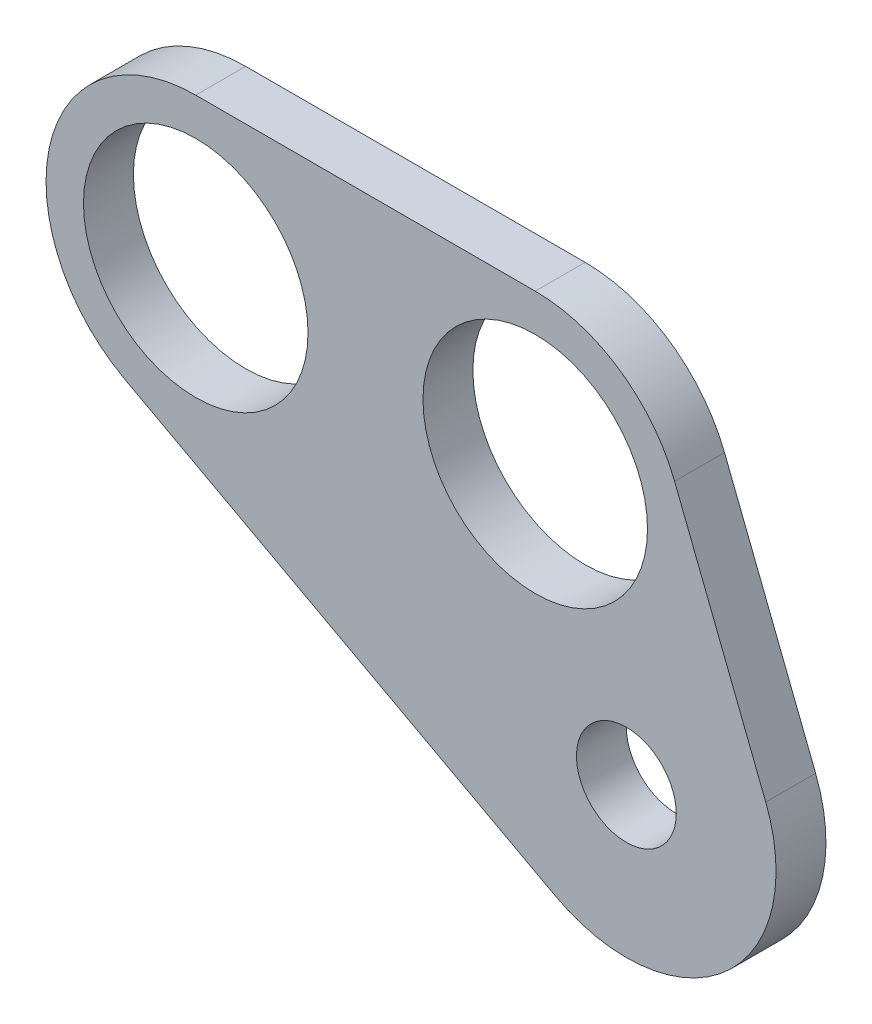
from build123d import *

# Parameters (mm, degrees)
BOSS_EXTRUDE1_DEPTH            = 6.35
F_1_1_DIAMETER_HOLE1_D         = 28.575
F_1_1_DIAMETER_HOLE1_DEPTH     = 25.4
F_1_1_DIAMETER_HOLE1_TIP       = 8.584796094
F_1_2_0_5_DIAMETER_HOLE1_D     = 12.7
F_1_2_0_5_DIAMETER_HOLE1_DEPTH = 25.4
F_1_2_0_5_DIAMETER_HOLE1_TIP   = 3.815464931


with BuildPart() as part:
    # Sketch1 → Boss-Extrude1 (new body)
    with BuildSketch(Plane.XY):
        with BuildLine():
            Line((-54.802639065, 48.60615919), (-11.597239065, 48.60615919))
            ThreePointArc((-11.597239065, 48.60615919), (-0.865369296, 45.295583298), (6.136456449, 36.514502629))
            Line((6.136456449, 36.514502629), (17.733695514, 6.958343439))
            ThreePointArc((17.733695514, 6.958343439), (12.633512254, -14.258221072), (-9.042758094, -16.766962338))
            Line((-9.042758094, -16.766962338), (-63.84539716, 12.789196852))
            ThreePointArc((-63.84539716, 12.789196852), (-73.273063161, 34.219412746), (-54.802639065, 48.60615919))
        make_face()
    extrude(amount=BOSS_EXTRUDE1_DEPTH)

    # 1 (1) Diameter Hole1
    with Locations(Plane.XY.offset(6.35)):
        with Locations((-54.802639065, 29.55615919), (-11.597239065, 29.55615919)):
            Hole(F_1_1_DIAMETER_HOLE1_D / 2, depth=F_1_1_DIAMETER_HOLE1_DEPTH)
            with Locations((0, 0, -(F_1_1_DIAMETER_HOLE1_DEPTH + F_1_1_DIAMETER_HOLE1_TIP / 2))):  # 118° drill point
                Cone(0, F_1_1_DIAMETER_HOLE1_D / 2, F_1_1_DIAMETER_HOLE1_TIP, mode=Mode.SUBTRACT)

    # 1/2 (0.5) Diameter Hole1
    with Locations(Plane.XY.offset(6.35)):
        with Locations((0, 0)):
            Hole(F_1_2_0_5_DIAMETER_HOLE1_D / 2, depth=F_1_2_0_5_DIAMETER_HOLE1_DEPTH)
            with Locations((0, 0, -(F_1_2_0_5_DIAMETER_HOLE1_DEPTH + F_1_2_0_5_DIAMETER_HOLE1_TIP / 2))):  # 118° drill point
                Cone(0, F_1_2_0_5_DIAMETER_HOLE1_D / 2, F_1_2_0_5_DIAMETER_HOLE1_TIP, mode=Mode.SUBTRACT)


solid = part.part
